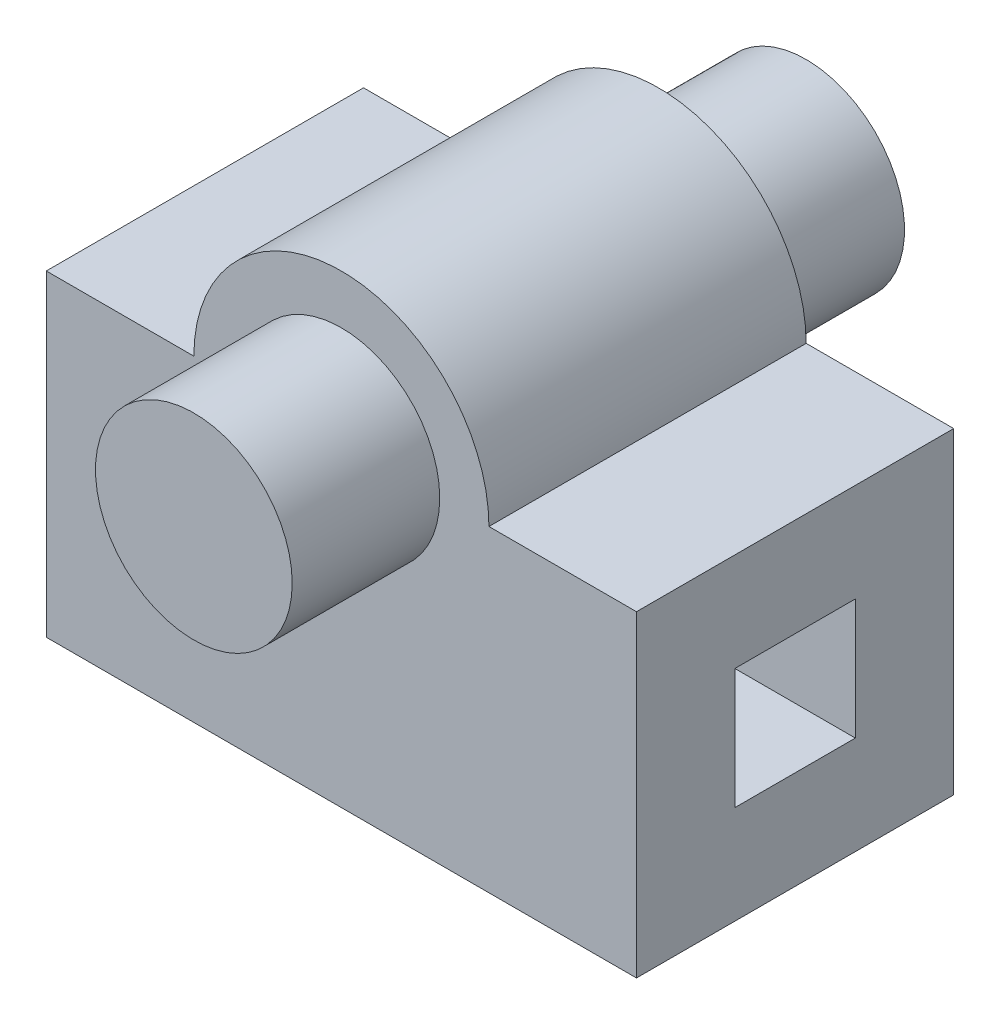
from build123d import *

# Parameters (mm, degrees)
SKETCH_1_W          = 120
SKETCH_1_H          = 64.5
EXTRUDE_1_DEPTH     = 44.5
SKETCH_2_W          = 24.5
SKETCH_2_H          = 24.5
CUT_EXTRUDE_1_DEPTH = 121
EXTRUDE_2_DEPTH     = 64.5
SKETCH_4_R          = 20
EXTRUDE_3_DEPTH     = 30
SKETCH_5_R          = 20
EXTRUDE_4_DEPTH     = 30
SKETCH_6_W          = 64.5
SKETCH_6_H          = 20
EXTRUDE_5_DEPTH     = 120


with BuildPart() as part:
    # 草图1 → 凸台-拉伸1 (new body)
    with BuildSketch(Plane(origin=(0, 0, 0), x_dir=(1, 0, 0), z_dir=(0, 1, 0))):
        Rectangle(SKETCH_1_W, SKETCH_1_H)
    extrude(amount=EXTRUDE_1_DEPTH)

    # 草图2 → 切除-拉伸1 (cut, through all)
    with BuildSketch(Plane(origin=(60, 0, 0), x_dir=(0, 0, -1), z_dir=(1, 0, 0))):
        with Locations((0, 12.25)):
            Rectangle(SKETCH_2_W, SKETCH_2_H)
    extrude(amount=-CUT_EXTRUDE_1_DEPTH, mode=Mode.SUBTRACT)

    # 草图3 → 凸台-拉伸2 (add)
    with BuildSketch(Plane.XY.offset(32.25)):
        with BuildLine():
            Line((-30, 44.5), (30, 44.5))
            ThreePointArc((30, 44.5), (0, 74.5), (-30, 44.5))
        make_face()
    extrude(amount=-EXTRUDE_2_DEPTH)

    # 草图4 → 凸台-拉伸3 (add)
    with BuildSketch(Plane.XY.offset(32.25)):
        with Locations((0, 44.5)):
            Circle(SKETCH_4_R)
    extrude(amount=EXTRUDE_3_DEPTH)

    # 草图5 → 凸台-拉伸4 (add)
    with BuildSketch(Plane(origin=(0, 0, -32.25), x_dir=(-1, 0, 0), z_dir=(0, 0, -1))):
        with Locations((0, 44.5)):
            Circle(SKETCH_5_R)
    extrude(amount=EXTRUDE_4_DEPTH)

    # 草图6 → 凸台-拉伸5 (add)
    with BuildSketch(Plane(origin=(60, 0, 0), x_dir=(0, 0, -1), z_dir=(1, 0, 0))):
        with Locations((0, -10)):
            Rectangle(SKETCH_6_W, SKETCH_6_H)
    extrude(amount=-EXTRUDE_5_DEPTH)


solid = part.part
